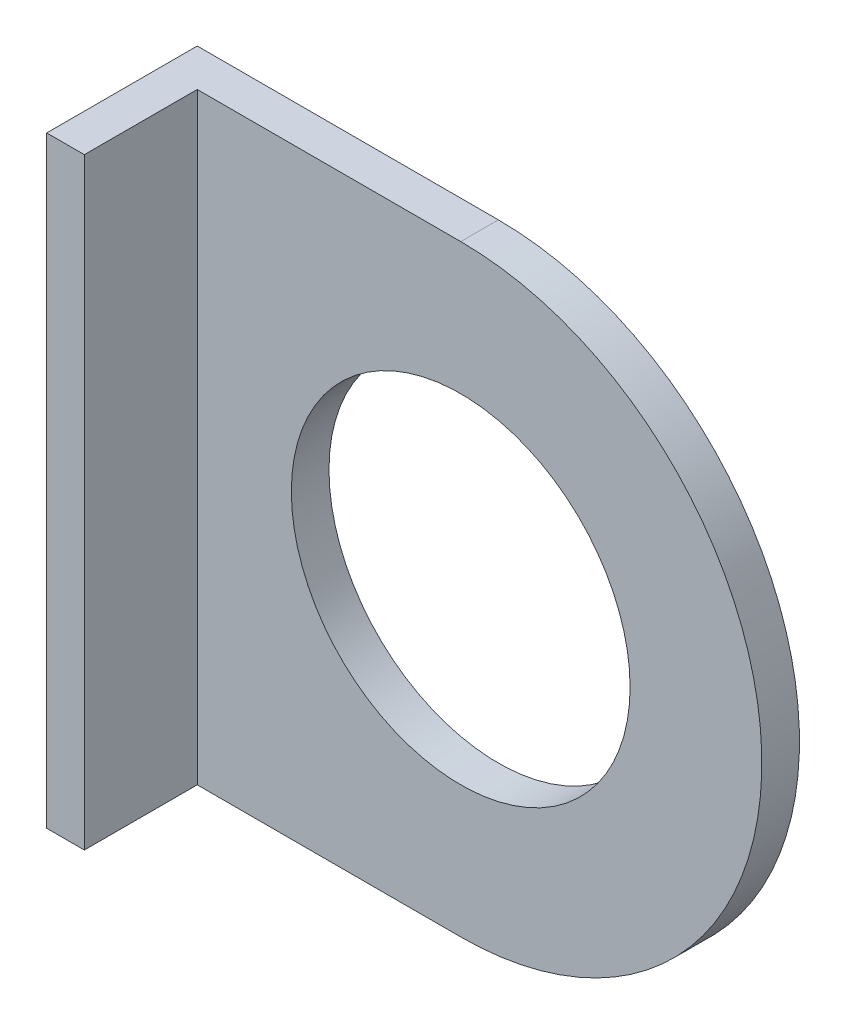
from build123d import *

# Parameters (mm, degrees)
SKETCH1_R           = 14.2875
BOSS_EXTRUDE1_DEPTH = 3.175
SKETCH2_W           = 3.175
SKETCH2_H           = 50.8
BOSS_EXTRUDE2_DEPTH = 9.525


with BuildPart() as part:
    # Sketch1 → Boss-Extrude1 (new body)
    with BuildSketch(Plane.XY.offset(309.267180797)):
        with BuildLine():
            Line((51.976784349, -201.484673508), (51.976784349, -150.684673508))
            Line((51.976784349, -150.684673508), (77.376784349, -150.684673508))
            ThreePointArc((77.376784349, -150.684673508), (102.776784349, -176.084673508), (77.376784349, -201.484673508))
            Line((77.376784349, -201.484673508), (51.976784349, -201.484673508))
        make_face()
        with Locations((77.376784349, -176.084673508)):
            Circle(SKETCH1_R, mode=Mode.SUBTRACT)
    extrude(amount=BOSS_EXTRUDE1_DEPTH)

    # Sketch2 → Boss-Extrude2 (add)
    with BuildSketch(Plane.XY.offset(312.442180797)):
        with Locations((53.564284349, -176.084673508)):
            Rectangle(SKETCH2_W, SKETCH2_H)
    extrude(amount=BOSS_EXTRUDE2_DEPTH)


solid = part.part
